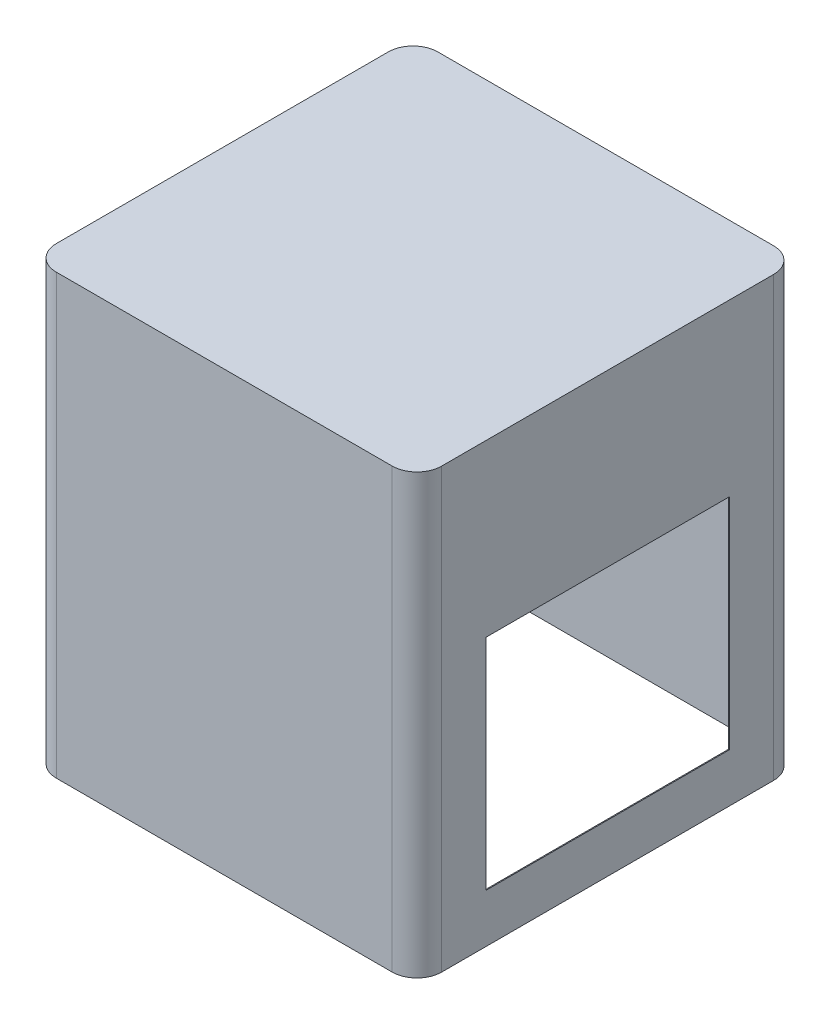
from build123d import *

# Parameters (mm, degrees)
SKETCH1_W           = 395.70484
SKETCH1_H           = 391.70484
BOSS_EXTRUDE1_DEPTH = 450
FILLET1_R           = 25.4
SHELL1_T            = -0.9525
CUT_EXTRUDE1_REACH  = 397.705
SKETCH2_W           = 250
SKETCH2_H           = 225


with BuildPart() as part:
    # Sketch1 → Boss-Extrude1 (new body)
    with BuildSketch(Plane(origin=(0, 0, 0), x_dir=(1, 0, 0), z_dir=(0, 1, 0))):
        Rectangle(SKETCH1_W, SKETCH1_H)
    extrude(amount=BOSS_EXTRUDE1_DEPTH)

    # Fillet1
    fillet1_edges = [part.edges().sort_by_distance(p)[0] for p in [
        (-197.85242, 225, -195.85242),
        (197.85242, 225, -195.85242),
        (197.85242, 225, 195.85242),
        (-197.85242, 225, 195.85242),
    ]]
    fillet(fillet1_edges, radius=FILLET1_R)

    # Shell1
    shell1_openings = [part.faces().sort_by_distance(p)[0] for p in [
        (0, 0, 0),
    ]]
    offset(amount=SHELL1_T, openings=shell1_openings, kind=Kind.INTERSECTION)

    # Sketch2 → Cut-Extrude1 (cut, up to next)
    with BuildSketch(Plane(origin=(197.85242, 0, -2), x_dir=(0, 0, 1), z_dir=(-1, 0, 0)), mode=Mode.PRIVATE) as cut_extrude1_sk1:
        with Locations((2, 162.5)):
            Rectangle(SKETCH2_W, SKETCH2_H)
    cut_extrude1_tool1 = extrude(cut_extrude1_sk1.sketch, amount=CUT_EXTRUDE1_REACH, mode=Mode.PRIVATE) & part.part
    add(cut_extrude1_tool1.solids().sort_by_distance((197.85242, 162.5, 0))[0], mode=Mode.SUBTRACT)


solid = part.part
